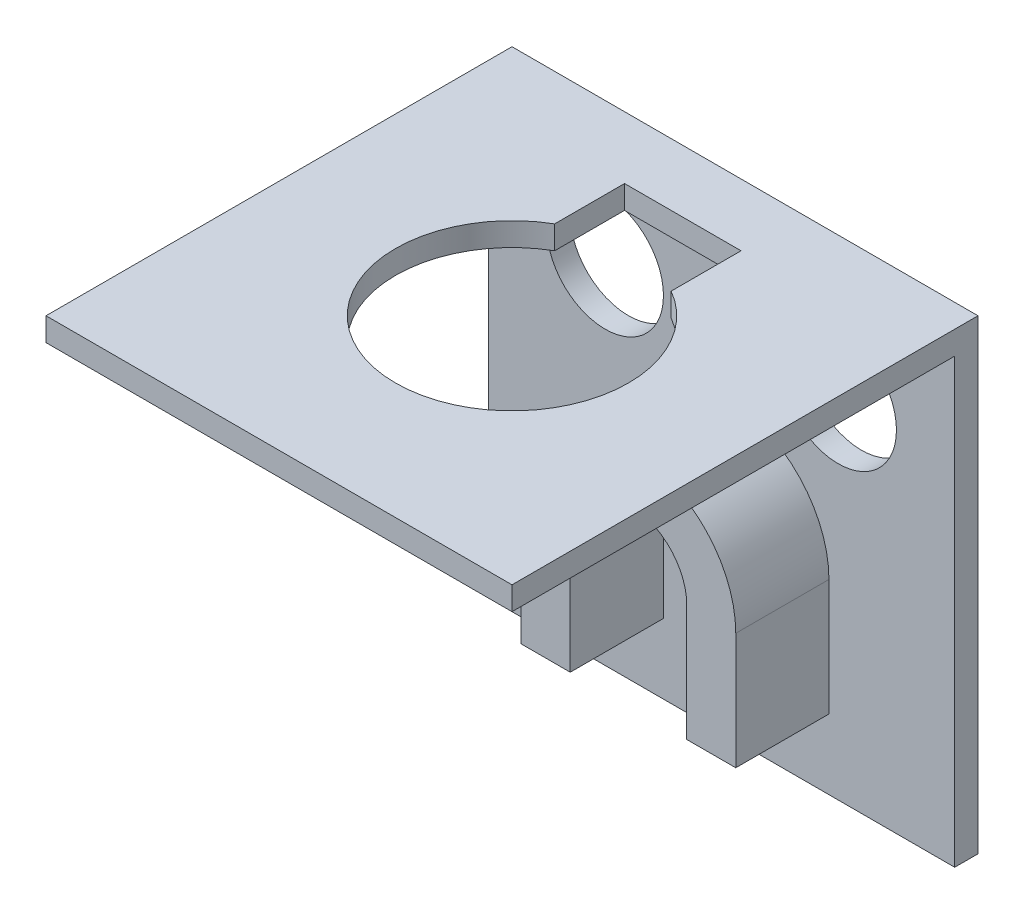
from build123d import *

# Parameters (mm, degrees)
SKETCH2_W           = 20
SKETCH2_H           = 20
BOSS_EXTRUDE1_DEPTH = 20
SKETCH3_W           = 20
SKETCH3_H           = 19
CUT_EXTRUDE1_DEPTH  = 19
SKETCH4_R           = 5
CUT_EXTRUDE2_DEPTH  = 17.5
BOSS_EXTRUDE2_DEPTH = 4
SKETCH10_R          = 2.5
CUT_EXTRUDE3_DEPTH  = 2
CUT_EXTRUDE4_DEPTH  = 2


with BuildPart() as part:
    # Sketch2 → Boss-Extrude1 (new body)
    with BuildSketch(Plane.XY):
        with Locations((10, 10)):
            Rectangle(SKETCH2_W, SKETCH2_H)
    extrude(amount=BOSS_EXTRUDE1_DEPTH)

    # Sketch3 → Cut-Extrude1 (cut)
    with BuildSketch(Plane.XY.offset(20)):
        with Locations((10, 9.5)):
            Rectangle(SKETCH3_W, SKETCH3_H)
    extrude(amount=-CUT_EXTRUDE1_DEPTH, mode=Mode.SUBTRACT)

    # Sketch4 → Cut-Extrude2 (cut)
    with BuildSketch(Plane.XZ.offset(-19)):
        with Locations((10, 10)):
            Circle(SKETCH4_R)
    extrude(amount=-CUT_EXTRUDE2_DEPTH, mode=Mode.SUBTRACT)

    # Sketch6 → Boss-Extrude2 (add)
    with BuildSketch(Plane.XY.offset(1)):
        with BuildLine():
            Line((7.5, 3), (7.5, 8))
            ThreePointArc((7.5, 8), (10, 10.5), (12.5, 8))
            Line((12.5, 8), (12.5, 3))
            Line((12.5, 3), (14.603533184, 3))
            Line((14.603533184, 3), (14.603533184, 8))
            ThreePointArc((14.603533184, 8), (10, 12.603533184), (5.396466816, 8))
            Line((5.396466816, 8), (5.396466816, 3))
            Line((5.396466816, 3), (7.5, 3))
        make_face()
    extrude(amount=BOSS_EXTRUDE2_DEPTH)

    # Sketch10 → Cut-Extrude3 (cut, through all)
    with BuildSketch(Plane.XY.offset(1)):
        with Locations((5, 15)):
            Circle(SKETCH10_R)
        with Locations((15, 15)):
            Circle(SKETCH10_R)
    extrude(amount=-CUT_EXTRUDE3_DEPTH, mode=Mode.SUBTRACT)

    # Sketch11 → Cut-Extrude4 (cut)
    with BuildSketch(Plane(origin=(0, 20, 0), x_dir=(1, 0, 0), z_dir=(0, 1, 0))):
        with BuildLine():
            Line((7.5, -5.669872981), (7.5, -2.669872981))
            Line((7.5, -2.669872981), (12.5, -2.669872981))
            Line((12.5, -2.669872981), (12.5, -5.669872981))
            ThreePointArc((12.5, -5.669872981), (10, -5), (7.5, -5.669872981))
        make_face()
    extrude(amount=-CUT_EXTRUDE4_DEPTH, mode=Mode.SUBTRACT)


solid = part.part
